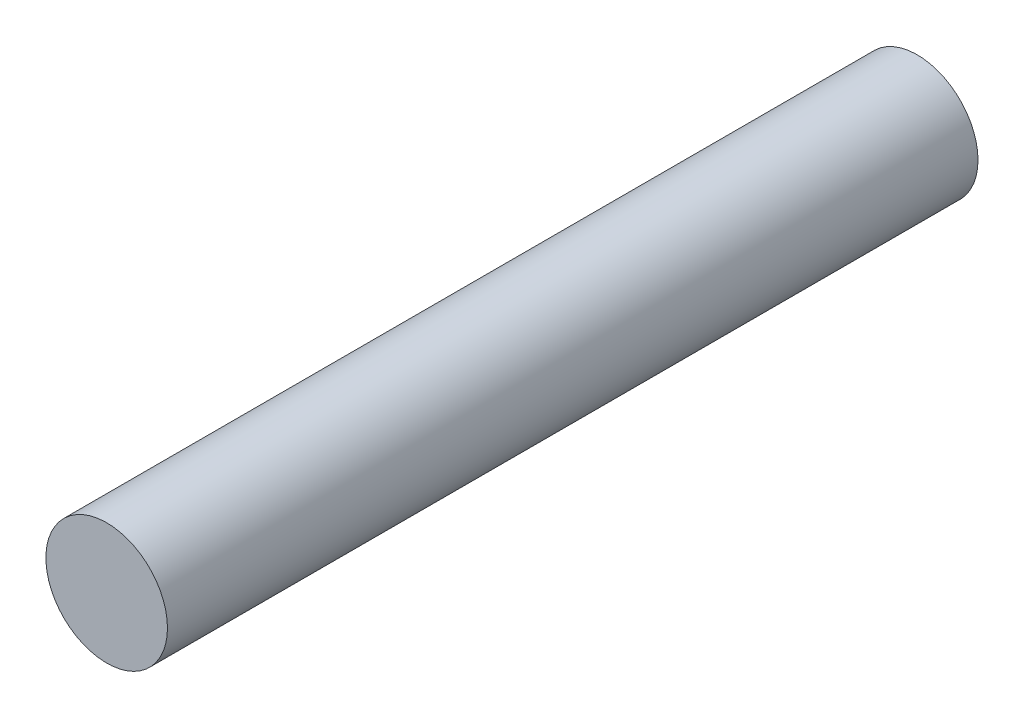
from build123d import *

# Parameters (mm, degrees)
CROQUIS1_R              = 7.5
SALIENTE_EXTRUIR1_DEPTH = 50


with BuildPart() as part:
    # Croquis1 → Saliente-Extruir1 (new body, symmetric)
    with BuildSketch(Plane.XY):
        Circle(CROQUIS1_R)
    extrude(amount=SALIENTE_EXTRUIR1_DEPTH, both=True)


solid = part.part
